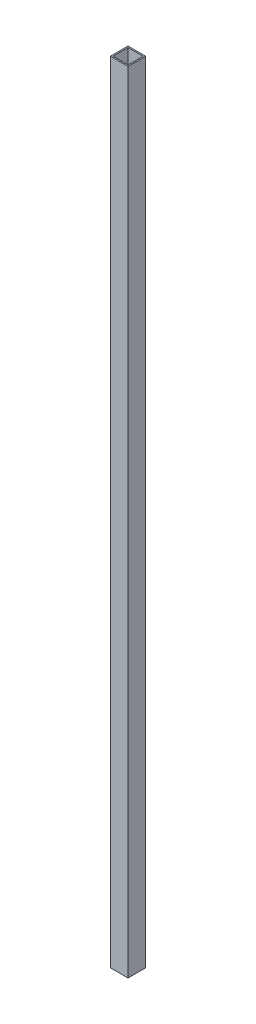
from build123d import *

# Parameters (mm, degrees)
SKETCH1_W           = 44.45
SKETCH1_H           = 44.45
SKETCH1_W_2         = 38.1
SKETCH1_H_2         = 38.1
BOSS_EXTRUDE1_DEPTH = 1985.9625


with BuildPart() as part:
    # Sketch1 → Boss-Extrude1 (new body)
    with BuildSketch(Plane(origin=(0, 0, 0), x_dir=(1, 0, 0), z_dir=(0, 1, 0))):
        with Locations((22.225, 22.225)):
            Rectangle(SKETCH1_W, SKETCH1_H)
        with Locations((22.225, 22.225)):
            Rectangle(SKETCH1_W_2, SKETCH1_H_2, mode=Mode.SUBTRACT)
    extrude(amount=BOSS_EXTRUDE1_DEPTH)


solid = part.part
